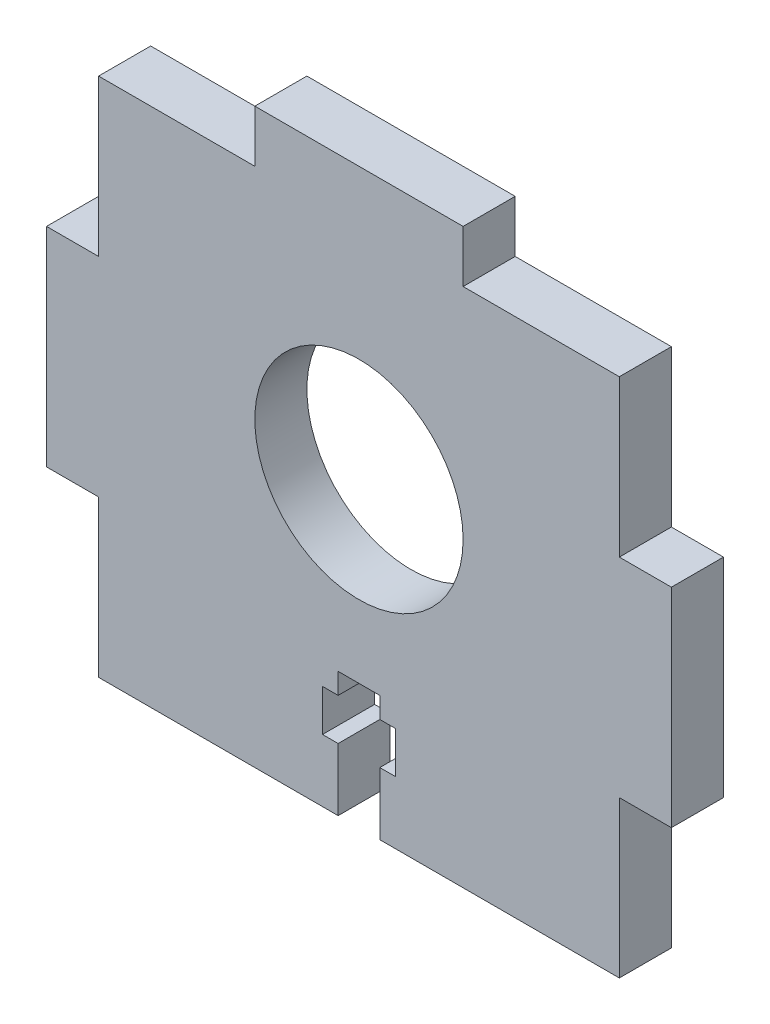
from build123d import *

# Parameters (mm, degrees)
BOSS_EXTRUDE1_DEPTH = 5
SKETCH3_R           = 10
CUT_EXTRUDE1_DEPTH  = 5


with BuildPart() as part:
    # Sketch2 → Boss-Extrude1 (new body)
    with BuildSketch(Plane.XY):
        Polygon((-26.751257452, 29.870014622), (-11.751257452, 29.870014622), (-11.751257452, 34.870014622), (8.248742548, 34.870014622), (8.248742548, 29.870014622), (23.248742548, 29.870014622), (23.248742548, 14.870014622), (28.248742548, 14.870014622), (28.248742548, -5.129985378), (23.248742548, -5.129985378), (23.248742548, -20.129985378), (-26.751257452, -20.129985378), (-26.751257452, -5.129985378), (-31.751257452, -5.129985378), (-31.751257452, 14.870014622), (-26.751257452, 14.870014622), align=None)
    extrude(amount=BOSS_EXTRUDE1_DEPTH)

    # Sketch3 → Cut-Extrude1 (cut)
    with BuildSketch(Plane.XY.offset(5)):
        with Locations((-1.751257452, 8.827972436)):
            Circle(SKETCH3_R)
        Polygon((-3.751257452, -20.129985378), (-3.751257452, -14.129985378), (-5.251257452, -14.129985378), (-5.251257452, -10.129985378), (-3.751257452, -10.129985378), (-3.751257452, -8.129985378), (0.248742548, -8.129985378), (0.248742548, -10.129985378), (1.748742548, -10.129985378), (1.748742548, -14.129985378), (0.248742548, -14.129985378), (0.248742548, -20.129985378), align=None)
    extrude(amount=-CUT_EXTRUDE1_DEPTH, mode=Mode.SUBTRACT)


solid = part.part
